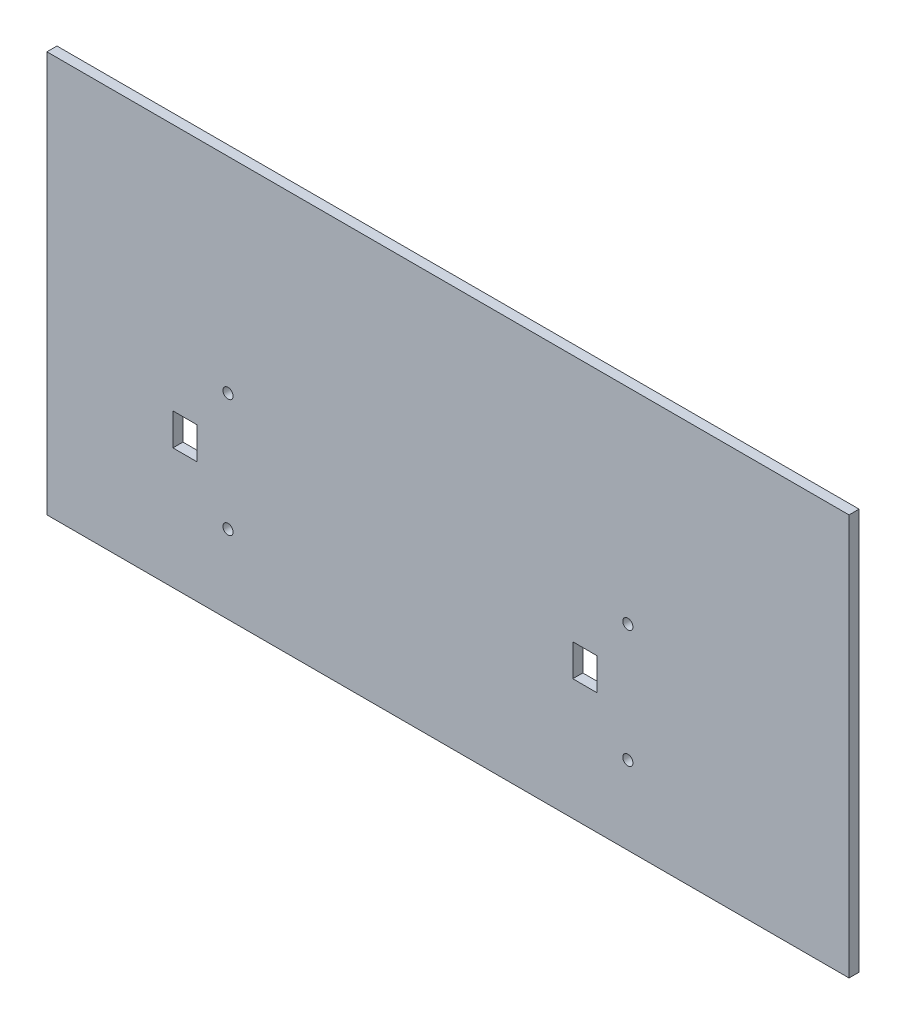
from build123d import *

# Parameters (mm, degrees)
SKETCH1_W           = 254
SKETCH1_H           = 127
BOSS_EXTRUDE1_DEPTH = 1.5875
SKETCH3_R           = 1.61
SKETCH3_W           = 7.62
SKETCH3_H           = 10.15
CUT_EXTRUDE2_DEPTH  = 5.08


with BuildPart() as part:
    # Sketch1 → Boss-Extrude1 (new body, symmetric)
    with BuildSketch(Plane.XY):
        Rectangle(SKETCH1_W, SKETCH1_H)
    extrude(amount=BOSS_EXTRUDE1_DEPTH, both=True)

    # Sketch3 → Cut-Extrude2 (cut)
    with BuildSketch(Plane(origin=(0, 0, -1.5875), x_dir=(-1, 0, 0), z_dir=(0, 0, -1))):
        with Locations((-56.955000009, -1.46)):
            Circle(SKETCH3_R)
        with Locations((-56.955000009, -38.74)):
            Circle(SKETCH3_R)
        with Locations((69.655000008, -38.74)):
            Circle(SKETCH3_R)
        with Locations((69.655000008, -1.46)):
            Circle(SKETCH3_R)
        with Locations((-43.320000018, -20.1)):
            Rectangle(SKETCH3_W, SKETCH3_H)
        with Locations((83.289999999, -20.1)):
            Rectangle(SKETCH3_W, SKETCH3_H)
    extrude(amount=-CUT_EXTRUDE2_DEPTH, mode=Mode.SUBTRACT)


solid = part.part
